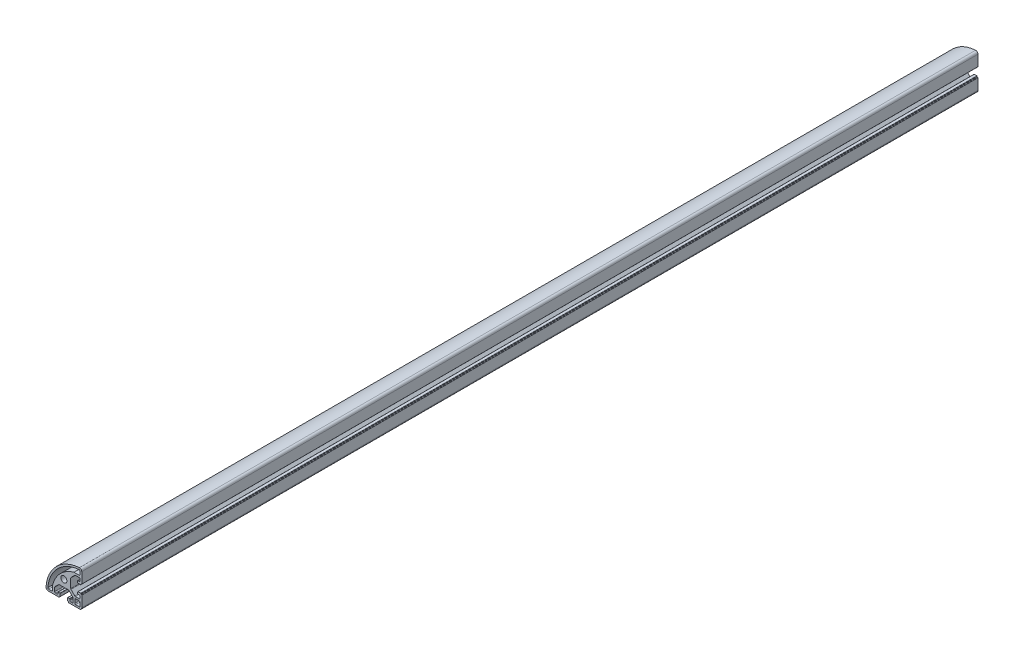
from build123d import *

# Parameters (mm, degrees)
SKETCH_1_R      = 3.4
EXTRUDE_1_DEPTH = 1000


with BuildPart() as part:
    # Эскиз1 → Бобышка-Вытянуть1 (new body)
    with BuildSketch(Plane.XY):
        with BuildLine():
            Line((10.25, -20), (17.5, -20))
            ThreePointArc((17.5, -20), (19.267766953, -19.267766953), (20, -17.5))
            Line((20, -17.5), (20, -10.25))
            Line((20, -10.25), (20, -5.4))
            ThreePointArc((20, -5.4), (19.912132034, -5.187867966), (19.7, -5.1))
            Line((19.7, -5.1), (19.3, -5.1))
            ThreePointArc((19.3, -5.1), (19.087867966, -5.012132034), (19, -4.8))
            Line((19, -4.8), (19, -4.4))
            ThreePointArc((19, -4.4), (18.912132034, -4.187867966), (18.7, -4.1))
            Line((18.7, -4.1), (15.8, -4.1))
            ThreePointArc((15.8, -4.1), (15.587867966, -4.187867966), (15.5, -4.4))
            Line((15.5, -4.4), (15.5, -6.3))
            ThreePointArc((15.5, -6.3), (15.587867966, -6.512132034), (15.8, -6.6))
            Line((15.8, -6.6), (17, -6.6))
            ThreePointArc((17, -6.6), (17.707106781, -6.892893219), (18, -7.6))
            Line((18, -7.6), (18, -9.25))
            ThreePointArc((18, -9.25), (17.707106781, -9.957106781), (17, -10.25))
            Line((17, -10.25), (12.864213562, -10.25))
            ThreePointArc((12.864213562, -10.25), (12.48153013, -10.173879533), (12.157106781, -9.957106781))
            Line((12.157106781, -9.957106781), (7.992893219, -5.792893219))
            ThreePointArc((7.992893219, -5.792893219), (7.776120467, -5.46846987), (7.7, -5.085786438))
            Line((7.7, -5.085786438), (7.7, 5.085786438))
            ThreePointArc((7.7, 5.085786438), (7.776120467, 5.46846987), (7.992893219, 5.792893219))
            Line((7.992893219, 5.792893219), (12.157106781, 9.957106781))
            ThreePointArc((12.157106781, 9.957106781), (12.48153013, 10.173879533), (12.864213562, 10.25))
            Line((12.864213562, 10.25), (17, 10.25))
            ThreePointArc((17, 10.25), (17.707106781, 9.957106781), (18, 9.25))
            Line((18, 9.25), (18, 7.6))
            ThreePointArc((18, 7.6), (17.707106781, 6.892893219), (17, 6.6))
            Line((17, 6.6), (15.8, 6.6))
            ThreePointArc((15.8, 6.6), (15.587867966, 6.512132034), (15.5, 6.3))
            Line((15.5, 6.3), (15.5, 4.4))
            ThreePointArc((15.5, 4.4), (15.587867966, 4.187867966), (15.8, 4.1))
            Line((15.8, 4.1), (18.7, 4.1))
            ThreePointArc((18.7, 4.1), (18.912132034, 4.187867966), (19, 4.4))
            Line((19, 4.4), (19, 4.8))
            ThreePointArc((19, 4.8), (19.087867966, 5.012132034), (19.3, 5.1))
            Line((19.3, 5.1), (19.7, 5.1))
            ThreePointArc((19.7, 5.1), (19.912132034, 5.187867966), (20, 5.4))
            Line((20, 5.4), (20, 10.25))
            Line((20, 10.25), (20, 17.416573868))
            ThreePointArc((20, 17.416573868), (19.207825128, 19.242315726), (17.333333333, 19.911012126))
            ThreePointArc((17.333333333, 19.911012126), (-8.284271247, 8.284271247), (-19.911012126, -17.333333333))
            ThreePointArc((-19.911012126, -17.333333333), (-19.242315726, -19.207825128), (-17.416573868, -20))
            Line((-17.416573868, -20), (-10.25, -20))
            Line((-10.25, -20), (-5.4, -20))
            ThreePointArc((-5.4, -20), (-5.187867966, -19.912132034), (-5.1, -19.7))
            Line((-5.1, -19.7), (-5.1, -19.3))
            ThreePointArc((-5.1, -19.3), (-5.012132034, -19.087867966), (-4.8, -19))
            Line((-4.8, -19), (-4.4, -19))
            ThreePointArc((-4.4, -19), (-4.187867966, -18.912132034), (-4.1, -18.7))
            Line((-4.1, -18.7), (-4.1, -15.8))
            ThreePointArc((-4.1, -15.8), (-4.187867966, -15.587867966), (-4.4, -15.5))
            Line((-4.4, -15.5), (-6.3, -15.5))
            ThreePointArc((-6.3, -15.5), (-6.512132034, -15.587867966), (-6.6, -15.8))
            Line((-6.6, -15.8), (-6.6, -17))
            ThreePointArc((-6.6, -17), (-6.892893219, -17.707106781), (-7.6, -18))
            Line((-7.6, -18), (-9.25, -18))
            ThreePointArc((-9.25, -18), (-9.957106781, -17.707106781), (-10.25, -17))
            Line((-10.25, -17), (-10.25, -12.864213562))
            ThreePointArc((-10.25, -12.864213562), (-10.173879533, -12.48153013), (-9.957106781, -12.157106781))
            Line((-9.957106781, -12.157106781), (-5.792893219, -7.992893219))
            ThreePointArc((-5.792893219, -7.992893219), (-5.46846987, -7.776120467), (-5.085786438, -7.7))
            Line((-5.085786438, -7.7), (5.085786438, -7.7))
            ThreePointArc((5.085786438, -7.7), (5.46846987, -7.776120467), (5.792893219, -7.992893219))
            Line((5.792893219, -7.992893219), (9.957106781, -12.157106781))
            ThreePointArc((9.957106781, -12.157106781), (10.173879533, -12.48153013), (10.25, -12.864213562))
            Line((10.25, -12.864213562), (10.25, -17))
            ThreePointArc((10.25, -17), (9.957106781, -17.707106781), (9.25, -18))
            Line((9.25, -18), (7.6, -18))
            ThreePointArc((7.6, -18), (6.892893219, -17.707106781), (6.6, -17))
            Line((6.6, -17), (6.6, -15.8))
            ThreePointArc((6.6, -15.8), (6.512132034, -15.587867966), (6.3, -15.5))
            Line((6.3, -15.5), (4.4, -15.5))
            ThreePointArc((4.4, -15.5), (4.187867966, -15.587867966), (4.1, -15.8))
            Line((4.1, -15.8), (4.1, -18.7))
            ThreePointArc((4.1, -18.7), (4.187867966, -18.912132034), (4.4, -19))
            Line((4.4, -19), (4.8, -19))
            ThreePointArc((4.8, -19), (5.012132034, -19.087867966), (5.1, -19.3))
            Line((5.1, -19.3), (5.1, -19.7))
            ThreePointArc((5.1, -19.7), (5.187867966, -19.912132034), (5.4, -20))
            Line((5.4, -20), (10.25, -20))
        make_face()
        Circle(SKETCH_1_R, mode=Mode.SUBTRACT)
        with BuildLine():
            Line((18, 16.878177829), (18, 13.447331922))
            ThreePointArc((18, 13.447331922), (17.707106781, 12.740225141), (17, 12.447331922))
            Line((17, 12.447331922), (11.274711974, 12.447331922))
            ThreePointArc((11.274711974, 12.447331922), (-3.758787848, 3.758787848), (-12.447331922, -11.274711974))
            Line((-12.447331922, -11.274711974), (-12.447331922, -17))
            ThreePointArc((-12.447331922, -17), (-12.740225141, -17.707106781), (-13.447331922, -18))
            Line((-13.447331922, -18), (-16.878177829, -18))
            ThreePointArc((-16.878177829, -18), (-17.613392451, -17.677834389), (-17.874885338, -16.918918919))
            ThreePointArc((-17.874885338, -16.918918919), (-6.870057685, 6.870057685), (16.918918919, 17.874885338))
            ThreePointArc((16.918918919, 17.874885338), (17.677834389, 17.613392451), (18, 16.878177829))
        make_face(mode=Mode.SUBTRACT)
        with BuildLine():
            Line((13.2, -12.2), (17, -12.2))
            ThreePointArc((17, -12.2), (17.707106781, -12.492893219), (18, -13.2))
            Line((18, -13.2), (18, -17))
            ThreePointArc((18, -17), (17.707106781, -17.707106781), (17, -18))
            Line((17, -18), (13.2, -18))
            ThreePointArc((13.2, -18), (12.492893219, -17.707106781), (12.2, -17))
            Line((12.2, -17), (12.2, -13.2))
            ThreePointArc((12.2, -13.2), (12.492893219, -12.492893219), (13.2, -12.2))
        make_face(mode=Mode.SUBTRACT)
    extrude(amount=EXTRUDE_1_DEPTH)


solid = part.part
